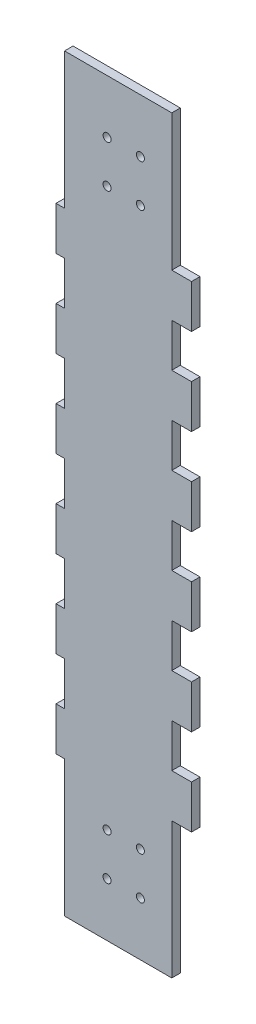
from build123d import *

# Parameters (mm, degrees)
BOSS_EXTRUDE1_DEPTH = 3.175
SKETCH2_R           = 1.5
CUT_EXTRUDE1_DEPTH  = 3.175


with BuildPart() as part:
    # Sketch1 → Boss-Extrude1 (new body)
    with BuildSketch(Plane.XY):
        Polygon((40, 279.4), (0, 279.4), (0, 228.6), (-3.175, 228.6), (-3.175, 212.436363636), (0, 212.436363636), (0, 196.272727273), (-3.175, 196.272727273), (-3.175, 180.109090909), (0, 180.109090909), (0, 163.945454545), (-3.175, 163.945454545), (-3.175, 147.781818182), (0, 147.781818182), (0, 131.618181818), (-3.175, 131.618181818), (-3.175, 115.454545455), (0, 115.454545455), (0, 99.290909091), (-3.175, 99.290909091), (-3.175, 83.127272727), (0, 83.127272727), (0, 66.963636364), (-3.175, 66.963636364), (-3.175, 50.8), (0, 50.8), (0, 0), (40, 0), (40, 50.8), (47.35, 50.8), (47.35, 66.963636364), (40, 66.963636364), (40, 83.127272727), (47.35, 83.127272727), (47.35, 99.290909091), (40, 99.290909091), (40, 115.454545455), (47.35, 115.454545455), (47.35, 131.618181818), (40, 131.618181818), (40, 147.781818182), (47.35, 147.781818182), (47.35, 163.945454545), (40, 163.945454545), (40, 180.109090909), (47.35, 180.109090909), (47.35, 196.272727273), (40, 196.272727273), (40, 212.436363636), (47.35, 212.436363636), (47.35, 228.6), (40, 228.6), align=None)
    extrude(amount=BOSS_EXTRUDE1_DEPTH)

    # Sketch2 → Cut-Extrude1 (cut)
    with BuildSketch(Plane.XY.offset(3.175)):
        with Locations((15.875, 20)):
            Circle(SKETCH2_R)
        with Locations((15.875, 35.75)):
            Circle(SKETCH2_R)
        with Locations((15.875, 243.65)):
            Circle(SKETCH2_R)
        with Locations((15.875, 259.4)):
            Circle(SKETCH2_R)
        with Locations((28.3, 20)):
            Circle(SKETCH2_R)
        with Locations((28.3, 35.75)):
            Circle(SKETCH2_R)
        with Locations((28.3, 243.65)):
            Circle(SKETCH2_R)
        with Locations((28.3, 259.4)):
            Circle(SKETCH2_R)
    extrude(amount=-CUT_EXTRUDE1_DEPTH, mode=Mode.SUBTRACT)


solid = part.part
